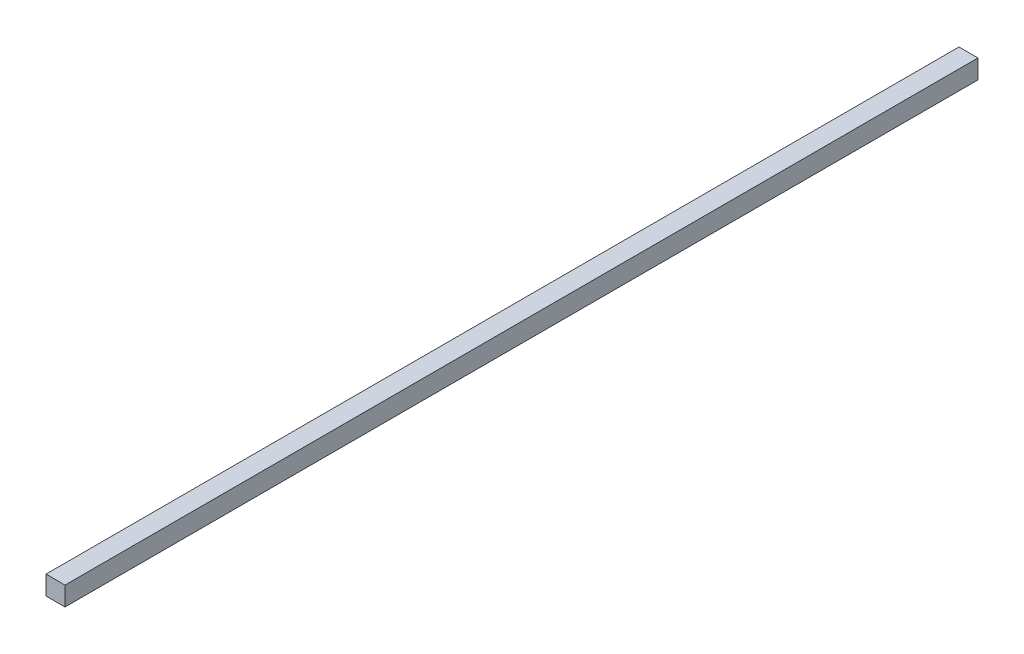
from build123d import *

# Parameters (mm, degrees)
SKETCH1_W           = 6.35
SKETCH1_H           = 6.35
BOSS_EXTRUDE1_DEPTH = 152.4


with BuildPart() as part:
    # Sketch1 → Boss-Extrude1 (new body, symmetric)
    with BuildSketch(Plane.XY):
        with Locations((-3.175, 3.175)):
            Rectangle(SKETCH1_W, SKETCH1_H)
    extrude(amount=BOSS_EXTRUDE1_DEPTH, both=True)


solid = part.part
